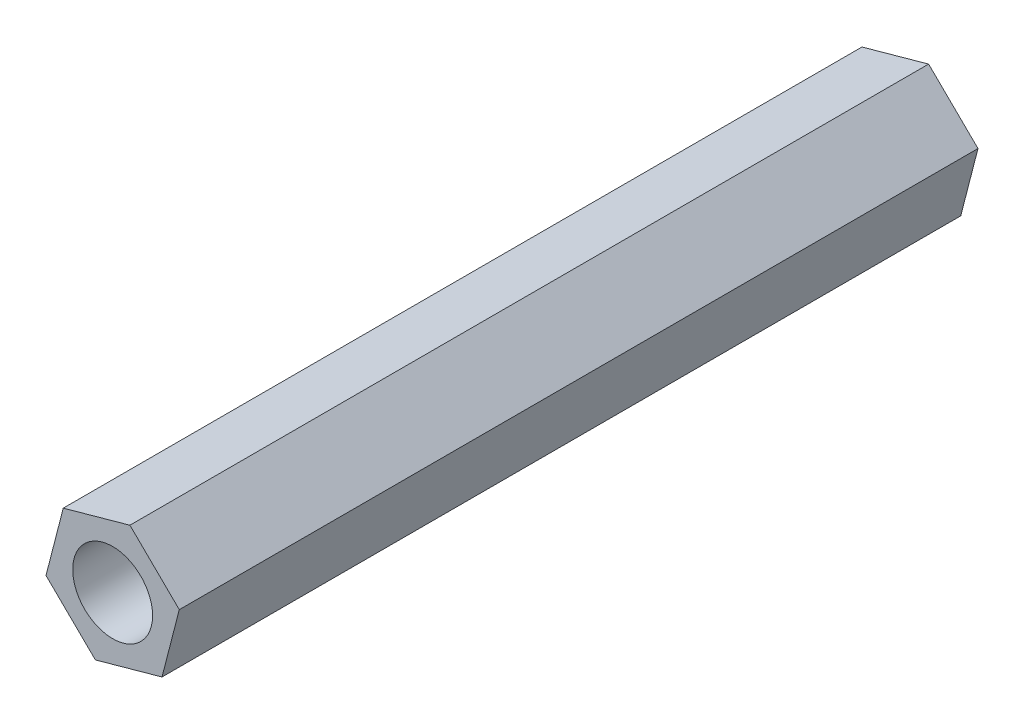
from build123d import *

# Parameters (mm, degrees)
EXTRUDE_1_DEPTH     = 20
SKETCH_2_R          = 1
CUT_EXTRUDE_1_DEPTH = 20


with BuildPart() as part:
    # 草图1 → 凸台-拉伸1 (new body)
    with BuildSketch(Plane.XY):
        Polygon((1.236137102, -1.213245674), (1.668770126, 0.463903296), (0.432633024, 1.67714897), (-1.236137102, 1.213245674), (-1.668770126, -0.463903296), (-0.432633024, -1.67714897), align=None)
    extrude(amount=EXTRUDE_1_DEPTH)

    # 草图2 → 切除-拉伸1 (cut)
    with BuildSketch(Plane.XY.offset(20)):
        Circle(SKETCH_2_R)
    extrude(amount=-CUT_EXTRUDE_1_DEPTH, mode=Mode.SUBTRACT)


solid = part.part
